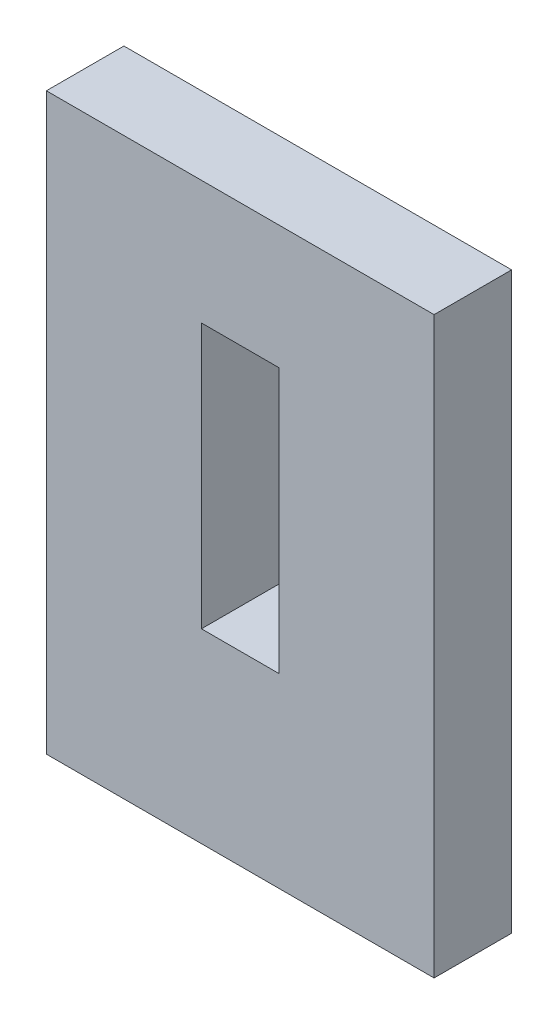
from build123d import *

# Parameters (mm, degrees)
SKETCH1_W           = 31.75
SKETCH1_H           = 47.047321622
SKETCH1_W_2         = 6.35
SKETCH1_H_2         = 21.6916
BOSS_EXTRUDE1_DEPTH = 6.35


with BuildPart() as part:
    # Sketch1 → Boss-Extrude1 (new body)
    with BuildSketch(Plane.XY):
        with Locations((15.875, 23.523660811)):
            Rectangle(SKETCH1_W, SKETCH1_H)
        with Locations((15.875, 26.0858)):
            Rectangle(SKETCH1_W_2, SKETCH1_H_2, mode=Mode.SUBTRACT)
    extrude(amount=BOSS_EXTRUDE1_DEPTH)


solid = part.part
